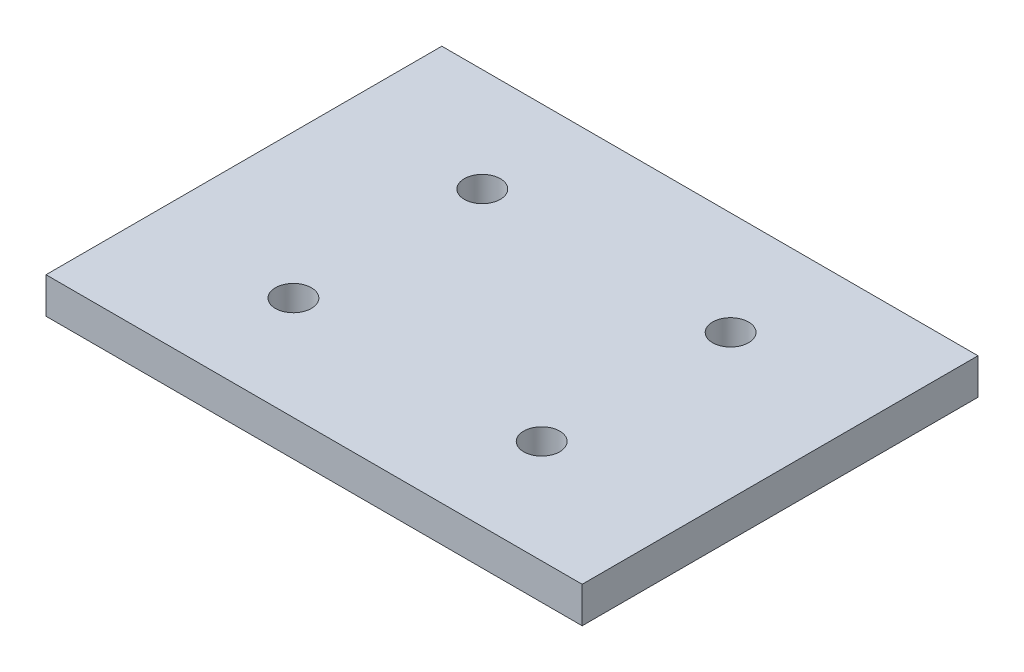
from build123d import *

# Parameters (mm, degrees)
SKETCH1_W           = 29.8
SKETCH1_H           = 22
BOSS_EXTRUDE1_DEPTH = 2
SKETCH2_R           = 1
CUT_EXTRUDE2_DEPTH  = 10


with BuildPart() as part:
    # Sketch1 → Boss-Extrude1 (new body)
    with BuildSketch(Plane(origin=(0, 0, 0), x_dir=(1, 0, 0), z_dir=(0, 1, 0))):
        Rectangle(SKETCH1_W, SKETCH1_H)
    extrude(amount=BOSS_EXTRUDE1_DEPTH)

    # Sketch2 → Cut-Extrude2 (cut)
    with BuildSketch(Plane.XZ):
        with Locations((6.9, -5.25)):
            Circle(SKETCH2_R)
        with Locations((-6.9, -5.25)):
            Circle(SKETCH2_R)
    cut_extrude2 = extrude(amount=-CUT_EXTRUDE2_DEPTH, mode=Mode.SUBTRACT)

    # Mirror1: Cut-Extrude2 across plane
    add(cut_extrude2.mirror(Plane(origin=(0, 0, 0), x_dir=(1, 0, 0), z_dir=(0, 0, -1))), mode=Mode.SUBTRACT)


solid = part.part
